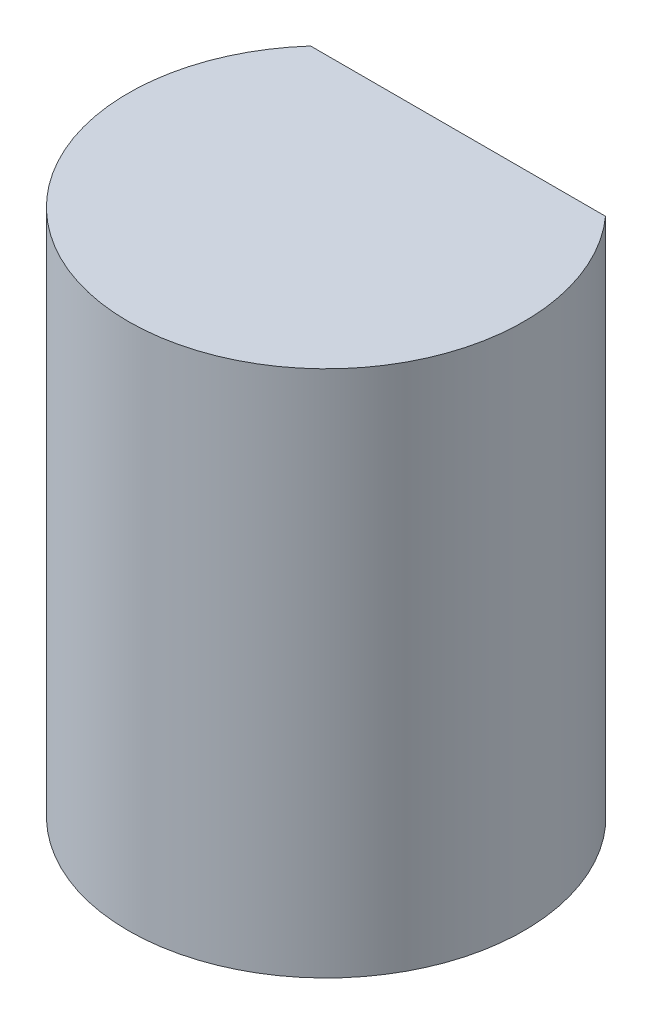
from build123d import *

# Parameters (mm, degrees)
SKETCH1_R           = 1.5
BOSS_EXTRUDE1_DEPTH = 4
CUT_EXTRUDE1_REACH  = 6
SKETCH6_W           = 2.236067978
SKETCH6_H           = 0.5


with BuildPart() as part:
    # Sketch1 → Boss-Extrude1 (new body)
    with BuildSketch(Plane(origin=(0, 0, 0), x_dir=(1, 0, 0), z_dir=(0, 1, 0))):
        Circle(SKETCH1_R)
    extrude(amount=BOSS_EXTRUDE1_DEPTH)

    # Sketch6 → Cut-Extrude1 (cut, up to next)
    with BuildSketch(Plane(origin=(0, 4, 0), x_dir=(1, 0, 0), z_dir=(0, 1, 0)), mode=Mode.PRIVATE) as cut_extrude1_sk1:
        with Locations((0, 1.25)):
            Rectangle(SKETCH6_W, SKETCH6_H)
    cut_extrude1_tool1 = extrude(cut_extrude1_sk1.sketch, amount=-CUT_EXTRUDE1_REACH, mode=Mode.PRIVATE) & part.part
    add(cut_extrude1_tool1.solids().sort_by_distance((0, 4, -1.25))[0], mode=Mode.SUBTRACT)


solid = part.part
